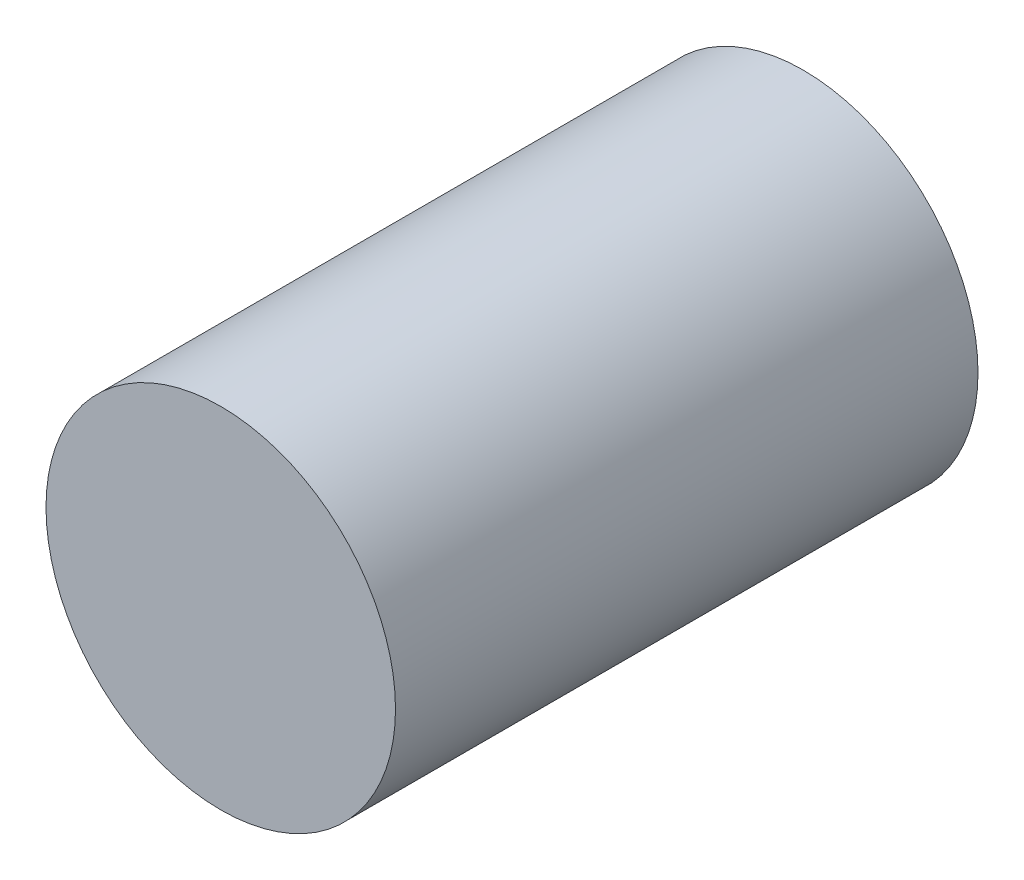
from build123d import *

# Parameters (mm, degrees)
SKETCH1_R           = 15
BOSS_EXTRUDE2_DEPTH = 50
SKETCH3_R           = 5
CUT_EXTRUDE2_DEPTH  = 50


with BuildPart() as part:
    # Sketch1 → Boss-Extrude2 (new body)
    with BuildSketch(Plane.XY):
        Circle(SKETCH1_R)
    extrude(amount=BOSS_EXTRUDE2_DEPTH)

    # Sketch3 → Cut-Extrude2 (cut)
    with BuildSketch(Plane(origin=(0, 0, 0), x_dir=(1, 0, 0), z_dir=(0, 1, 0))):
        with Locations((0, -24.925423447)):
            Circle(SKETCH3_R)
    extrude(amount=-CUT_EXTRUDE2_DEPTH, mode=Mode.SUBTRACT)


solid = part.part
